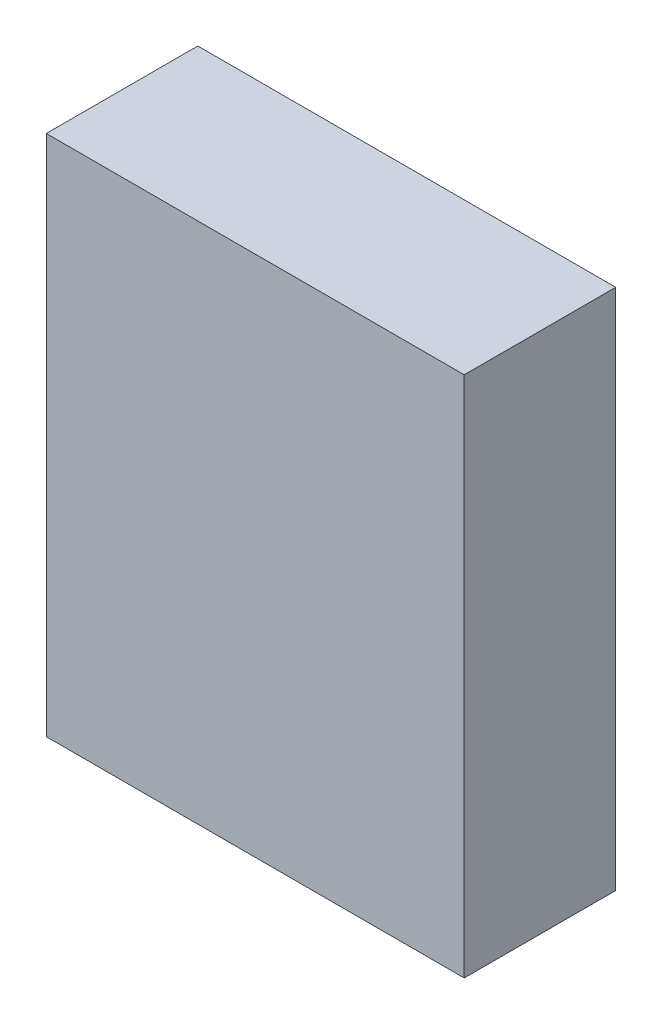
from build123d import *

# Parameters (mm, degrees)
SKETCH1_W           = 80
SKETCH1_H           = 100
BOSS_EXTRUDE1_DEPTH = 29


with BuildPart() as part:
    # Sketch1 → Boss-Extrude1 (new body)
    with BuildSketch(Plane.XY):
        Rectangle(SKETCH1_W, SKETCH1_H)
    extrude(amount=BOSS_EXTRUDE1_DEPTH)


solid = part.part
